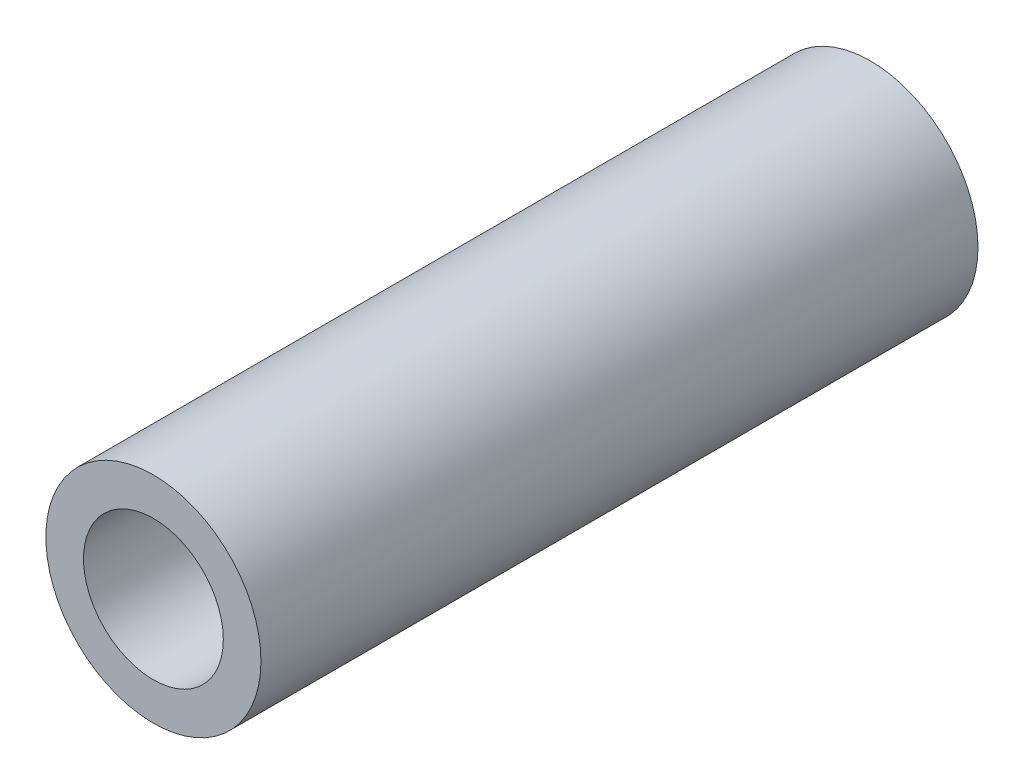
from build123d import *

# Parameters (mm, degrees)
SZKIC1_R                    = 3
SZKIC1_R_2                  = 1.95
DODANIE_WYCI_GNI_CIE1_DEPTH = 20


with BuildPart() as part:
    # Szkic1 → Dodanie-wyciągnięcie1 (new body)
    with BuildSketch(Plane.XY):
        Circle(SZKIC1_R)
        Circle(SZKIC1_R_2, mode=Mode.SUBTRACT)
    extrude(amount=DODANIE_WYCI_GNI_CIE1_DEPTH)


solid = part.part
